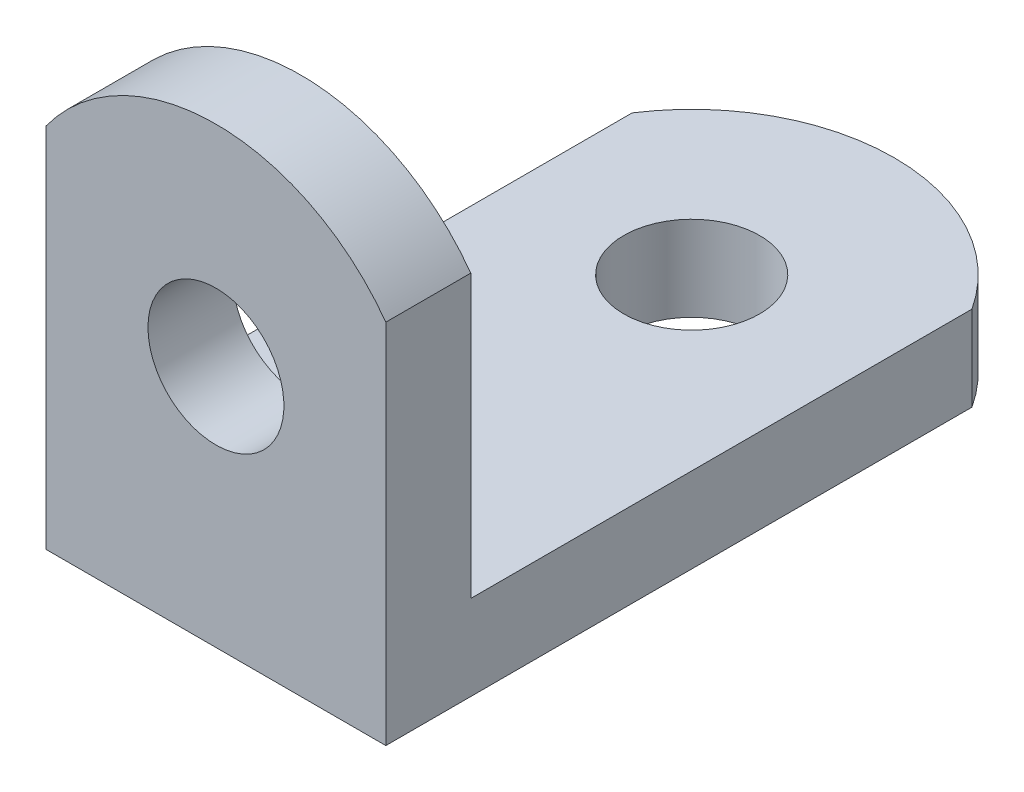
from build123d import *

# Parameters (mm, degrees)
SKETCH1_W           = 12.7
SKETCH1_H           = 25.4
BOSS_EXTRUDE1_DEPTH = 3.175
SKETCH2_W           = 12.7
SKETCH2_H           = 3.175
BOSS_EXTRUDE2_DEPTH = 13.7922
SKETCH3_R           = 2.54
CUT_EXTRUDE1_DEPTH  = 4.175
CUT_EXTRUDE2_DEPTH  = 4.175
SKETCH5_R           = 2.54
CUT_EXTRUDE3_DEPTH  = 4.175
CUT_EXTRUDE4_DEPTH  = 4.175


with BuildPart() as part:
    # Sketch1 → Boss-Extrude1 (new body)
    with BuildSketch(Plane(origin=(0, 0, 0), x_dir=(1, 0, 0), z_dir=(0, 1, 0))):
        with Locations((-19.111794294, -7.819421488)):
            Rectangle(SKETCH1_W, SKETCH1_H)
    extrude(amount=BOSS_EXTRUDE1_DEPTH)

    # Sketch2 → Boss-Extrude2 (add)
    with BuildSketch(Plane(origin=(0, 3.175, 0), x_dir=(1, 0, 0), z_dir=(0, 1, 0))):
        with Locations((-19.111794294, -18.931921488)):
            Rectangle(SKETCH2_W, SKETCH2_H)
    extrude(amount=BOSS_EXTRUDE2_DEPTH)

    # Sketch3 → Cut-Extrude1 (cut, through all)
    with BuildSketch(Plane(origin=(0, 3.175, 0), x_dir=(1, 0, 0), z_dir=(0, 1, 0))):
        with Locations((-19.111794294, -2.739421488)):
            Circle(SKETCH3_R)
    extrude(amount=-CUT_EXTRUDE1_DEPTH, mode=Mode.SUBTRACT)

    # Sketch4 → Cut-Extrude2 (cut, through all)
    with BuildSketch(Plane(origin=(0, 3.175, 0), x_dir=(1, 0, 0), z_dir=(0, 1, 0))):
        with BuildLine():
            Line((-25.461794294, 4.880578512), (-12.761794294, 4.880578512))
            Line((-12.761794294, 4.880578512), (-12.761794294, 1.385127101))
            ThreePointArc((-12.761794294, 1.385127101), (-19.111794294, 4.832526813), (-25.461794294, 1.385127101))
            Line((-25.461794294, 1.385127101), (-25.461794294, 4.880578512))
        make_face()
    extrude(amount=-CUT_EXTRUDE2_DEPTH, mode=Mode.SUBTRACT)

    # Sketch5 → Cut-Extrude3 (cut, through all)
    with BuildSketch(Plane(origin=(0, 0, 17.344421488), x_dir=(-1, 0, 0), z_dir=(0, 0, -1))):
        with Locations((19.111794294, 9.0932)):
            Circle(SKETCH5_R)
    extrude(amount=-CUT_EXTRUDE3_DEPTH, mode=Mode.SUBTRACT)

    # Sketch6 → Cut-Extrude4 (cut, through all)
    with BuildSketch(Plane(origin=(0, 0, 17.344421488), x_dir=(-1, 0, 0), z_dir=(0, 0, -1))):
        with BuildLine():
            Line((25.461794294, 16.9672), (12.761794294, 16.9672))
            Line((12.761794294, 16.9672), (12.761794294, 13.704377903))
            ThreePointArc((12.761794294, 13.704377903), (19.111794294, 16.940840515), (25.461794294, 13.704377903))
            Line((25.461794294, 13.704377903), (25.461794294, 16.9672))
        make_face()
    extrude(amount=-CUT_EXTRUDE4_DEPTH, mode=Mode.SUBTRACT)


solid = part.part
